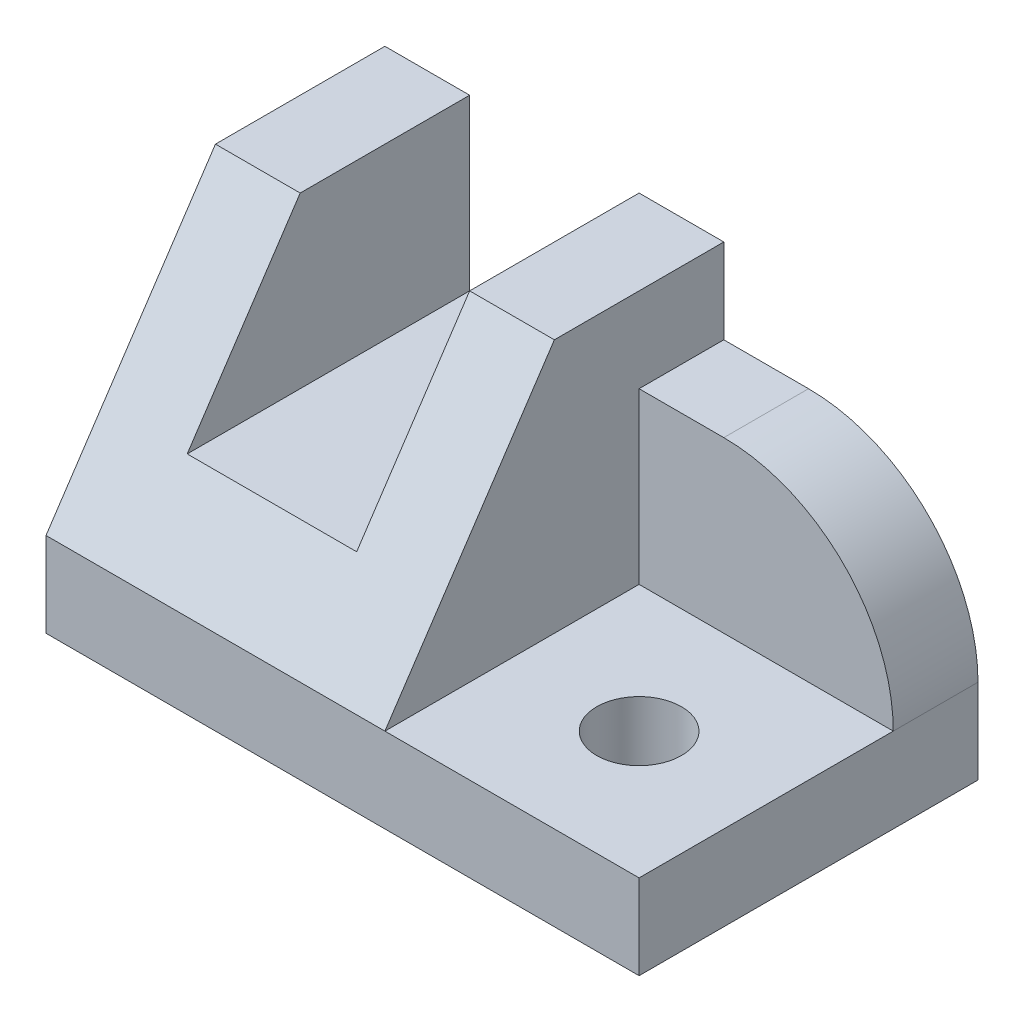
from build123d import *

# Parameters (mm, degrees)
BOSS_EXTRUDE1_DEPTH            = 40
SKETCH2_W                      = 40
SKETCH2_H                      = 30
BOSS_EXTRUDE2_DEPTH            = 20
BOSS_EXTRUDE3_DEPTH            = 30
CUT_EXTRUDE1_DEPTH             = 30
SKETCH5_W                      = 70
SKETCH5_H                      = 40
BOSS_EXTRUDE4_DEPTH            = 10
SKETCH6_W                      = 20
SKETCH6_H                      = 20
CUT_EXTRUDE2_DEPTH             = 41
F_10_0_10_DIAMETER_HOLE1_D     = 10
F_10_0_10_DIAMETER_HOLE1_DEPTH = 40
FILLET1_R                      = 20


with BuildPart() as part:
    # Sketch1 → Boss-Extrude1 (new body)
    with BuildSketch(Plane(origin=(0, 0, 0), x_dir=(0, -1, 0), z_dir=(-1, 0, 0))):
        Polygon((-10, 0), (-40, -20), (-10, -20), align=None)
    extrude(amount=-BOSS_EXTRUDE1_DEPTH)

    # Sketch2 → Boss-Extrude2 (add)
    with BuildSketch(Plane(origin=(0, 0, -20), x_dir=(-1, 0, 0), z_dir=(0, 0, -1))):
        with Locations((-20, 25)):
            Rectangle(SKETCH2_W, SKETCH2_H)
    extrude(amount=BOSS_EXTRUDE2_DEPTH)

    # Sketch3 → Boss-Extrude3 (add)
    with BuildSketch(Plane(origin=(40, 0, 0), x_dir=(0, 0, -1), z_dir=(1, 0, 0))):
        Polygon((40, 10), (0, 10), (20, 40), (40, 40), align=None)
    extrude(amount=BOSS_EXTRUDE3_DEPTH)

    # Sketch4 → Cut-Extrude1 (cut)
    with BuildSketch(Plane(origin=(70, 0, 0), x_dir=(0, 0, -1), z_dir=(1, 0, 0))):
        Polygon((20, 40), (0, 10), (30, 10), (30, 30), (40, 30), (40, 40), align=None)
    extrude(amount=-CUT_EXTRUDE1_DEPTH, mode=Mode.SUBTRACT)

    # Sketch5 → Boss-Extrude4 (add)
    with BuildSketch(Plane.XZ.offset(-10)):
        with Locations((35, -20)):
            Rectangle(SKETCH5_W, SKETCH5_H)
    extrude(amount=BOSS_EXTRUDE4_DEPTH)

    # Sketch6 → Cut-Extrude2 (cut, through all)
    with BuildSketch(Plane(origin=(0, 0, -40), x_dir=(-1, 0, 0), z_dir=(0, 0, -1))):
        with Locations((-20, 30)):
            Rectangle(SKETCH6_W, SKETCH6_H)
    extrude(amount=-CUT_EXTRUDE2_DEPTH, mode=Mode.SUBTRACT)

    # Ø10.0 (10) Diameter Hole1
    with Locations(Plane(origin=(0, 0, 0), x_dir=(-1, 0, 0), z_dir=(0, -1, 0))):
        with Locations((-55, 15)):
            Hole(F_10_0_10_DIAMETER_HOLE1_D / 2, depth=F_10_0_10_DIAMETER_HOLE1_DEPTH)

    # Fillet1
    fillet1_edges = [part.edges().sort_by_distance(p)[0] for p in [
        (70, 30, -35),
    ]]
    fillet(fillet1_edges, radius=FILLET1_R)


solid = part.part
